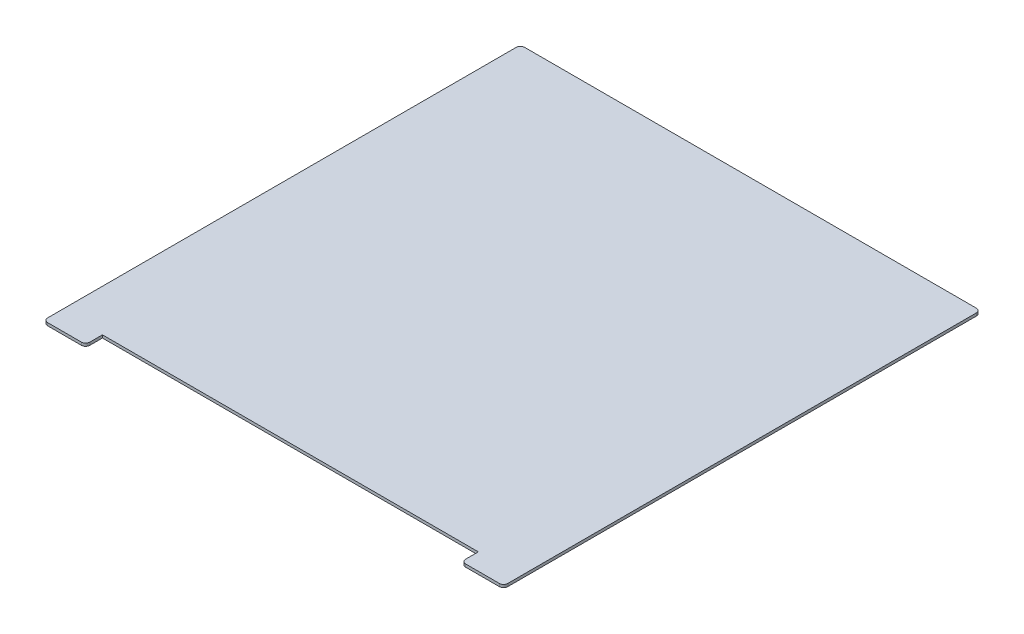
from build123d import *

# Parameters (mm, degrees)
BOSS_EXTRUDE1_DEPTH = 2
FILLET1_R           = 3


with BuildPart() as part:
    # Sketch1 → Boss-Extrude1 (new body)
    with BuildSketch(Plane(origin=(0, 0, 0), x_dir=(1, 0, 0), z_dir=(0, 1, 0))):
        Polygon((-268, -197.649746193), (-268, -185.649746193), (0, -185.649746193), (0, -197.649746193), (30, -197.649746193), (30, 142.350253807), (-298, 142.350253807), (-298, -197.649746193), align=None)
    extrude(amount=BOSS_EXTRUDE1_DEPTH)

    # Fillet1
    fillet1_edges = [part.edges().sort_by_distance(p)[0] for p in [
        (-298, 1, -142.350253807),
        (30, 1, -142.350253807),
        (30, 1, 197.649746193),
        (0, 1, 197.649746193),
        (-268, 1, 197.649746193),
        (-298, 1, 197.649746193),
    ]]
    fillet(fillet1_edges, radius=FILLET1_R)


solid = part.part
